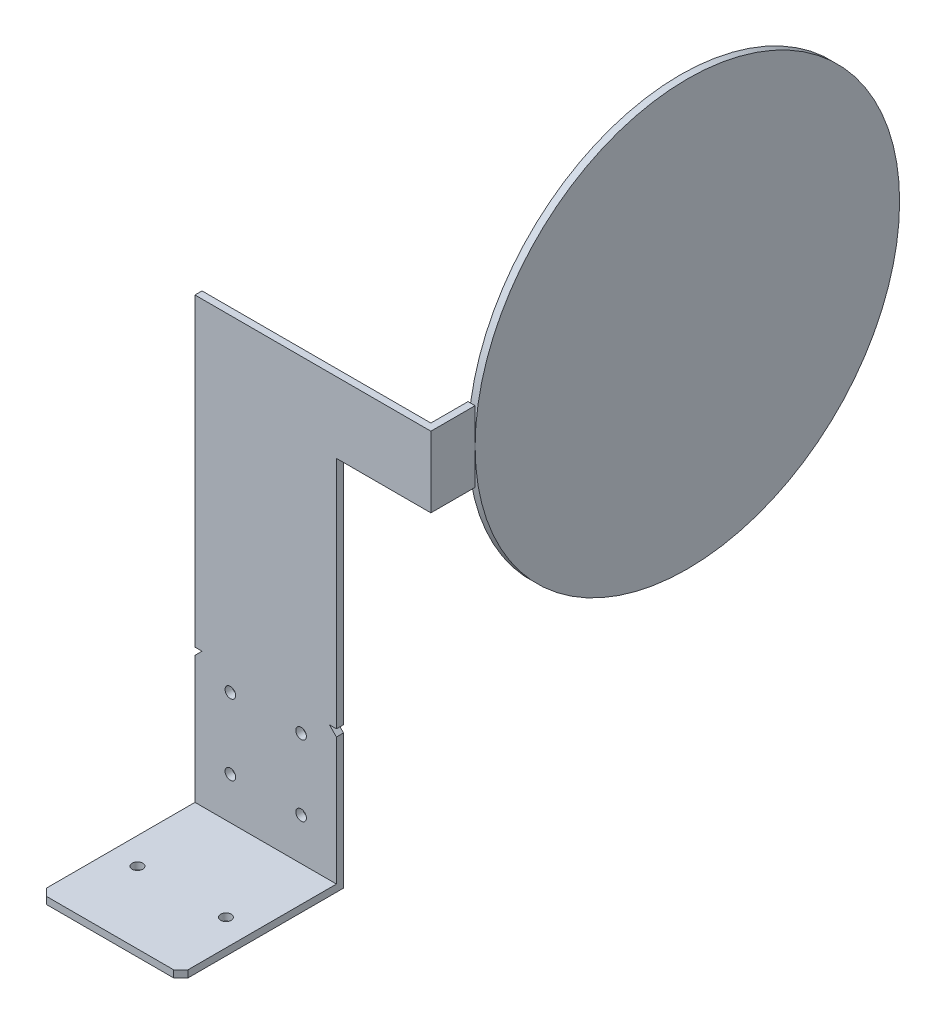
from build123d import *

# Parameters (mm, degrees)
EXTRUDE1_DEPTH      = 40
EXTRUDE2_REACH      = 42
SKETCH2_R           = 1.5
EXTRUDE3_REACH      = 48
SKETCH3_R           = 1.5
CHAMFER1_SIZE       = 2
SKETCH9_W           = 40
SKETCH9_H           = 86.21
BOSS_EXTRUDE1_DEPTH = 2
SKETCH11_W          = 26.69
SKETCH11_H          = 20
BOSS_EXTRUDE2_DEPTH = 2
SKETCH13_W          = 10.5
SKETCH13_H          = 20
BOSS_EXTRUDE3_DEPTH = 2
SKETCH14_R          = 60
BOSS_EXTRUDE4_DEPTH = 2


with BuildPart() as part:
    # Sketch1 → Extrude1 (new body)
    with BuildSketch(Plane(origin=(0, 0, 0), x_dir=(0, 0, -1), z_dir=(1, 0, 0))):
        Polygon((0, 0), (0, 38), (2, 38), (2, -2), (-44, -2), (-44, 0), align=None)
    extrude(amount=EXTRUDE1_DEPTH)

    # Sketch2 → Extrude2 (cut, up to next)
    with BuildSketch(Plane(origin=(0, -2, 0), x_dir=(-1, 0, 0), z_dir=(0, -1, 0)), mode=Mode.PRIVATE) as extrude2_sk1:
        with Locations((-32.5, -23.75)):
            Circle(SKETCH2_R)
    extrude2_tool1 = extrude(extrude2_sk1.sketch, amount=-EXTRUDE2_REACH, mode=Mode.PRIVATE) & part.part
    add(extrude2_tool1.solids().sort_by_distance((32.5, -2, 23.75))[0], mode=Mode.SUBTRACT)
    # Sketch2 → Extrude2 (cut, up to next)
    with BuildSketch(Plane(origin=(0, -2, 0), x_dir=(-1, 0, 0), z_dir=(0, -1, 0)), mode=Mode.PRIVATE) as extrude2_sk2:
        with Locations((-7.5, -23.75)):
            Circle(SKETCH2_R)
    extrude2_tool2 = extrude(extrude2_sk2.sketch, amount=-EXTRUDE2_REACH, mode=Mode.PRIVATE) & part.part
    add(extrude2_tool2.solids().sort_by_distance((7.5, -2, 23.75))[0], mode=Mode.SUBTRACT)

    # Sketch3 → Extrude3 (cut, up to next)
    with BuildSketch(Plane(origin=(0, 0, -2), x_dir=(-1, 0, 0), z_dir=(0, 0, -1)), mode=Mode.PRIVATE) as extrude3_sk1:
        with Locations((-10, 31.9)):
            Circle(SKETCH3_R)
    extrude3_tool1 = extrude(extrude3_sk1.sketch, amount=-EXTRUDE3_REACH, mode=Mode.PRIVATE) & part.part
    add(extrude3_tool1.solids().sort_by_distance((10, 31.9, -2))[0], mode=Mode.SUBTRACT)
    # Sketch3 → Extrude3 (cut, up to next)
    with BuildSketch(Plane(origin=(0, 0, -2), x_dir=(-1, 0, 0), z_dir=(0, 0, -1)), mode=Mode.PRIVATE) as extrude3_sk2:
        with Locations((-30, 31.9)):
            Circle(SKETCH3_R)
    extrude3_tool2 = extrude(extrude3_sk2.sketch, amount=-EXTRUDE3_REACH, mode=Mode.PRIVATE) & part.part
    add(extrude3_tool2.solids().sort_by_distance((30, 31.9, -2))[0], mode=Mode.SUBTRACT)
    # Sketch3 → Extrude3 (cut, up to next)
    with BuildSketch(Plane(origin=(0, 0, -2), x_dir=(-1, 0, 0), z_dir=(0, 0, -1)), mode=Mode.PRIVATE) as extrude3_sk3:
        with Locations((-30, 11.9)):
            Circle(SKETCH3_R)
    extrude3_tool3 = extrude(extrude3_sk3.sketch, amount=-EXTRUDE3_REACH, mode=Mode.PRIVATE) & part.part
    add(extrude3_tool3.solids().sort_by_distance((30, 11.9, -2))[0], mode=Mode.SUBTRACT)
    # Sketch3 → Extrude3 (cut, up to next)
    with BuildSketch(Plane(origin=(0, 0, -2), x_dir=(-1, 0, 0), z_dir=(0, 0, -1)), mode=Mode.PRIVATE) as extrude3_sk4:
        with Locations((-10, 11.9)):
            Circle(SKETCH3_R)
    extrude3_tool4 = extrude(extrude3_sk4.sketch, amount=-EXTRUDE3_REACH, mode=Mode.PRIVATE) & part.part
    add(extrude3_tool4.solids().sort_by_distance((10, 11.9, -2))[0], mode=Mode.SUBTRACT)

    # Chamfer1
    chamfer1_edges = [part.edges().sort_by_distance(p)[0] for p in [
        (40, 38, -1),
        (0, 38, -1),
        (40, -1, 44),
        (0, -1, 44),
    ]]
    chamfer(chamfer1_edges, length=CHAMFER1_SIZE)

    # Sketch9 → Boss-Extrude1 (add)
    with BuildSketch(Plane(origin=(0, 0, -2), x_dir=(-1, 0, 0), z_dir=(0, 0, -1))):
        with Locations((-20, 81.105)):
            Rectangle(SKETCH9_W, SKETCH9_H)
    extrude(amount=-BOSS_EXTRUDE1_DEPTH)

    # Sketch11 → Boss-Extrude2 (add)
    with BuildSketch(Plane(origin=(0, 0, -2), x_dir=(-1, 0, 0), z_dir=(0, 0, -1))):
        with Locations((-53.345, 114.21)):
            Rectangle(SKETCH11_W, SKETCH11_H)
    extrude(amount=-BOSS_EXTRUDE2_DEPTH)

    # Sketch13 → Boss-Extrude3 (add)
    with BuildSketch(Plane(origin=(66.69, 0, 0), x_dir=(0, 0, -1), z_dir=(1, 0, 0))):
        with Locations((7.25, 114.21)):
            Rectangle(SKETCH13_W, SKETCH13_H)
    extrude(amount=-BOSS_EXTRUDE3_DEPTH)


with BuildPart() as body_2:
    # Sketch14 → Boss-Extrude4 (new body)
    with BuildSketch(Plane(origin=(66.69, 0, 0), x_dir=(0, 0, -1), z_dir=(1, 0, 0))):
        with Locations((72.5, 114.21)):
            Circle(SKETCH14_R)
    extrude(amount=-BOSS_EXTRUDE4_DEPTH)


solid = Compound([part.part, body_2.part])
